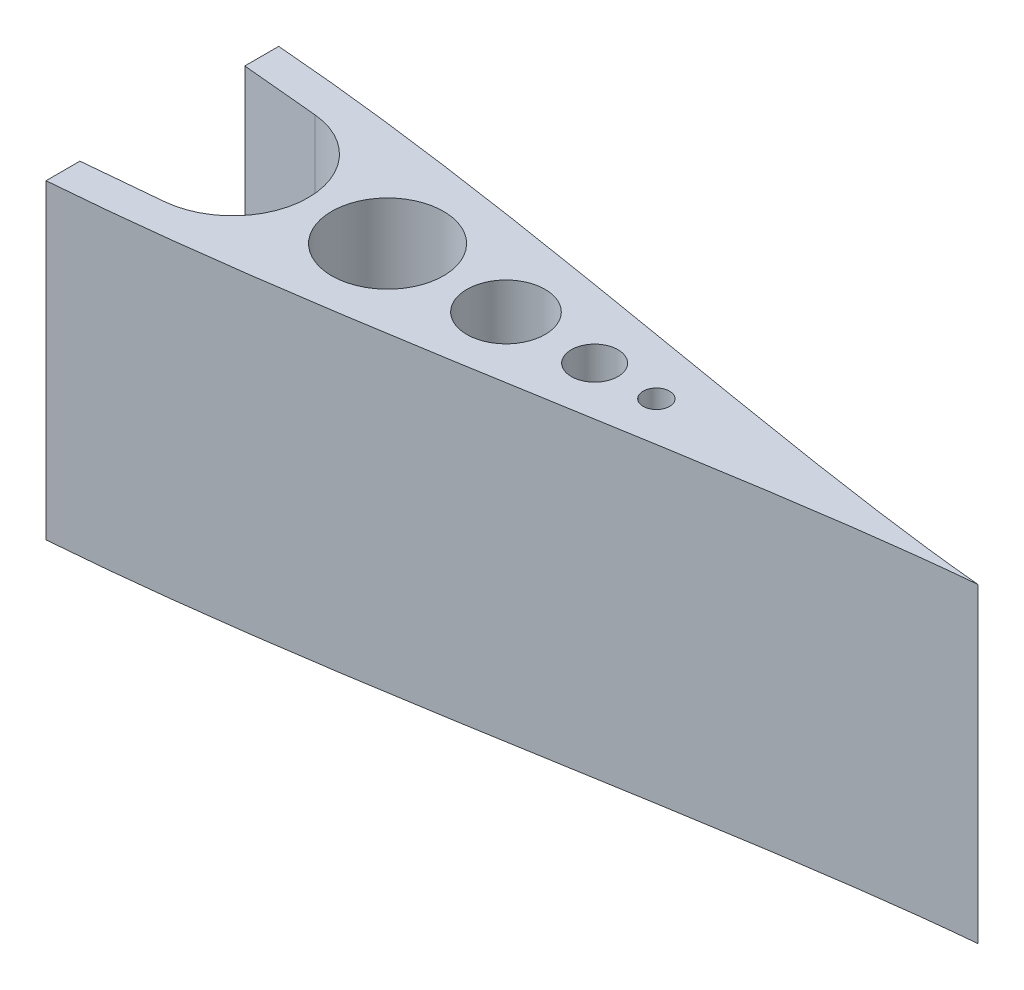
from build123d import *

# Parameters (mm, degrees)
SKETCH1_R           = 5.715
SKETCH1_R_2         = 9.131011462
SKETCH1_R_3         = 6.392333333
SKETCH1_R_4         = 3.81
SKETCH1_R_5         = 2.159
BOSS_EXTRUDE1_DEPTH = 50.8
CUT_EXTRUDE1_DEPTH  = 51.8000001


with BuildPart() as part:
    # Sketch1 → Boss-Extrude1 (new body)
    with BuildSketch(Plane(origin=(0, 0, 0), x_dir=(1, 0, 0), z_dir=(0, 1, 0))):
        with BuildLine():
            add(Edge.make_bspline(
                [(-106.482983395, 7e-09), (-106.481988205, 0.336221447), (-106.427915569, 1.172470852), (-106.105951464, 2.643099269), (-105.314009735, 4.475217408), (-103.897531119, 6.504348419), (-101.808045378, 8.571651332), (-99.066717841, 10.567556704), (-95.719803188, 12.4267473), (-91.817332429, 14.111441711), (-87.406701835, 15.599318162), (-82.531907012, 16.877133323), (-77.234149654, 17.93743562), (-71.552607098, 18.776740572), (-65.525147606, 19.395460586), (-59.188591418, 19.79657403), (-52.57905308, 19.986276316), (-45.732001964, 19.972865837), (-38.682363694, 19.76732247), (-31.464522928, 19.382552478), (-24.112335149, 18.833317467), (-16.659115821, 18.136000968), (-9.137634043, 17.308302017), (-1.580112881, 16.368906014), (5.98177291, 15.337213534), (13.516891029, 14.232999407), (20.994645609, 13.076129848), (28.384968739, 11.886210001), (35.658323251, 10.682336314), (42.785702907, 9.482759124), (49.738647425, 8.304637787), (56.489265684, 7.163760718), (63.010281114, 6.074356699), (69.275076728, 5.048841412), (75.257781106, 4.097692071), (80.933343311, 3.229317249), (86.277669376, 2.449846213), (91.267618323, 1.763292049), (95.881607116, 1.17122476), (100.098099776, 0.673119164), (103.673185129, 0.290516392), (105.83614122, 0.081745654), (106.733370691, 7e-09)],
                knots=[0.5, 0.5, 0.5, 0.5, 0.502166769, 0.505390167, 0.509655974, 0.514947682, 0.521244711, 0.528520886, 0.536744945, 0.54588136, 0.555890751, 0.566730119, 0.57835299, 0.590709588, 0.603747039, 0.617409572, 0.631638768, 0.646373793, 0.661551658, 0.677107483, 0.692974771, 0.709085713, 0.725371443, 0.741762353, 0.758188398, 0.774579367, 0.790865214, 0.806976332, 0.822843867, 0.838400002, 0.853578262, 0.868313774, 0.882543568, 0.896206835, 0.909245173, 0.92160287, 0.933227116, 0.944068236, 0.954079898, 0.963219316, 0.971447445, 0.977251074, 0.977251074, 0.977251074, 0.977251074], degree=3))
            add(Edge.make_bspline(
                [(-106.482983395, -7e-09), (-106.481988205, -0.336221447), (-106.427915569, -1.172470852), (-106.105951463, -2.643099269), (-105.314009735, -4.475217408), (-103.897531118, -6.504348419), (-101.808045378, -8.571651332), (-99.06671784, -10.567556704), (-95.719803188, -12.4267473), (-91.817332429, -14.111441711), (-87.406701835, -15.599318162), (-82.531907011, -16.877133323), (-77.234149654, -17.93743562), (-71.552607098, -18.776740572), (-65.525147605, -19.395460586), (-59.188591417, -19.79657403), (-52.57905308, -19.986276316), (-45.732001964, -19.972865837), (-38.682363694, -19.76732247), (-31.464522928, -19.382552478), (-24.112335148, -18.833317467), (-16.659115821, -18.136000968), (-9.137634043, -17.308302017), (-1.580112881, -16.368906014), (5.98177291, -15.337213534), (13.516891029, -14.232999407), (20.99464561, -13.076129848), (28.384968739, -11.886210001), (35.658323251, -10.682336314), (42.785702907, -9.482759124), (49.738647426, -8.304637787), (56.489265684, -7.163760718), (63.010281115, -6.074356699), (69.275076728, -5.048841412), (75.257781106, -4.097692071), (80.933343311, -3.229317249), (86.277669376, -2.449846213), (91.267618323, -1.763292049), (95.881607116, -1.17122476), (100.098099776, -0.673119164), (103.673185129, -0.290516392), (105.83614122, -0.081745654), (106.733370691, -7e-09)],
                knots=[0.5, 0.5, 0.5, 0.5, 0.502166769, 0.505390167, 0.509655974, 0.514947682, 0.521244711, 0.528520886, 0.536744945, 0.54588136, 0.555890751, 0.566730119, 0.57835299, 0.590709588, 0.603747039, 0.617409572, 0.631638768, 0.646373793, 0.661551658, 0.677107483, 0.692974771, 0.709085713, 0.725371443, 0.741762353, 0.758188398, 0.774579367, 0.790865214, 0.806976332, 0.822843867, 0.838400002, 0.853578262, 0.868313774, 0.882543568, 0.896206835, 0.909245173, 0.92160287, 0.933227116, 0.944068236, 0.954079898, 0.963219316, 0.971447445, 0.977251074, 0.977251074, 0.977251074, 0.977251074], degree=3))
        make_face()
        with BuildLine():
            ThreePointArc((-88.703779951, 0), (-92.937113284, -4.233333333), (-97.170446617, 0))
            ThreePointArc((-97.170446617, 0), (-92.937113284, 4.233333333), (-88.703779951, 0))
        make_face(mode=Mode.SUBTRACT)
        with Locations((-71.77044662, 0)):
            Circle(SKETCH1_R, mode=Mode.SUBTRACT)
        with BuildLine():
            ThreePointArc((-45.540838593, -15.24), (-60.780838593, 0), (-45.540838593, 15.24))
            ThreePointArc((-45.540838593, 15.24), (-44.126098565, 15.174192257), (-42.723576496, 14.977337356))
            Line((-42.723576496, 14.977337356), (-13.847320134, 12.285108666))
            ThreePointArc((-13.847320134, 12.285108666), (-2.65431439, 0), (-13.847320134, -12.285108666))
            Line((-13.847320134, -12.285108666), (-42.723576496, -14.977337356))
            ThreePointArc((-42.723576496, -14.977337356), (-44.126098565, -15.174192257), (-45.540838593, -15.24))
        make_face(mode=Mode.SUBTRACT)
        with Locations((10.310172634, 0)):
            Circle(SKETCH1_R_2, mode=Mode.SUBTRACT)
        with Locations((29.643517429, 0)):
            Circle(SKETCH1_R_3, mode=Mode.SUBTRACT)
        with Locations((44.126269567, 0)):
            Circle(SKETCH1_R_4, mode=Mode.SUBTRACT)
        with Locations((54.210398224, 0)):
            Circle(SKETCH1_R_5, mode=Mode.SUBTRACT)
        with BuildLine():
            add(Edge.make_bspline(
                [(-106.482983395, 7e-09), (-106.481988205, 0.336221447), (-106.427915569, 1.172470852), (-106.105951464, 2.643099269), (-105.314009735, 4.475217408), (-103.897531119, 6.504348419), (-101.808045378, 8.571651332), (-99.066717841, 10.567556704), (-95.719803188, 12.4267473), (-91.817332429, 14.111441711), (-87.406701835, 15.599318162), (-82.531907012, 16.877133323), (-77.234149654, 17.93743562), (-71.552607098, 18.776740572), (-65.525147606, 19.395460586), (-59.188591418, 19.79657403), (-52.57905308, 19.986276316), (-45.732001964, 19.972865837), (-38.682363694, 19.76732247), (-31.464522928, 19.382552478), (-24.112335149, 18.833317467), (-16.659115821, 18.136000968), (-9.137634043, 17.308302017), (-1.580112881, 16.368906014), (5.98177291, 15.337213534), (13.516891029, 14.232999407), (20.994645609, 13.076129848), (28.384968739, 11.886210001), (35.658323251, 10.682336314), (42.785702907, 9.482759124), (49.738647425, 8.304637787), (56.489265684, 7.163760718), (63.010281114, 6.074356699), (69.275076728, 5.048841412), (75.257781106, 4.097692071), (80.933343311, 3.229317249), (86.277669376, 2.449846213), (91.267618323, 1.763292049), (95.881607116, 1.17122476), (100.098099776, 0.673119164), (103.673185129, 0.290516392), (105.83614122, 0.081745654), (106.733370691, 7e-09)],
                knots=[0.5, 0.5, 0.5, 0.5, 0.502166769, 0.505390167, 0.509655974, 0.514947682, 0.521244711, 0.528520886, 0.536744945, 0.54588136, 0.555890751, 0.566730119, 0.57835299, 0.590709588, 0.603747039, 0.617409572, 0.631638768, 0.646373793, 0.661551658, 0.677107483, 0.692974771, 0.709085713, 0.725371443, 0.741762353, 0.758188398, 0.774579367, 0.790865214, 0.806976332, 0.822843867, 0.838400002, 0.853578262, 0.868313774, 0.882543568, 0.896206835, 0.909245173, 0.92160287, 0.933227116, 0.944068236, 0.954079898, 0.963219316, 0.971447445, 0.977251074, 0.977251074, 0.977251074, 0.977251074], degree=3))
            add(Edge.make_bspline(
                [(-106.482983395, -7e-09), (-106.481988205, -0.336221447), (-106.427915569, -1.172470852), (-106.105951463, -2.643099269), (-105.314009735, -4.475217408), (-103.897531118, -6.504348419), (-101.808045378, -8.571651332), (-99.06671784, -10.567556704), (-95.719803188, -12.4267473), (-91.817332429, -14.111441711), (-87.406701835, -15.599318162), (-82.531907011, -16.877133323), (-77.234149654, -17.93743562), (-71.552607098, -18.776740572), (-65.525147605, -19.395460586), (-59.188591417, -19.79657403), (-52.57905308, -19.986276316), (-45.732001964, -19.972865837), (-38.682363694, -19.76732247), (-31.464522928, -19.382552478), (-24.112335148, -18.833317467), (-16.659115821, -18.136000968), (-9.137634043, -17.308302017), (-1.580112881, -16.368906014), (5.98177291, -15.337213534), (13.516891029, -14.232999407), (20.99464561, -13.076129848), (28.384968739, -11.886210001), (35.658323251, -10.682336314), (42.785702907, -9.482759124), (49.738647426, -8.304637787), (56.489265684, -7.163760718), (63.010281115, -6.074356699), (69.275076728, -5.048841412), (75.257781106, -4.097692071), (80.933343311, -3.229317249), (86.277669376, -2.449846213), (91.267618323, -1.763292049), (95.881607116, -1.17122476), (100.098099776, -0.673119164), (103.673185129, -0.290516392), (105.83614122, -0.081745654), (106.733370691, -7e-09)],
                knots=[0.5, 0.5, 0.5, 0.5, 0.502166769, 0.505390167, 0.509655974, 0.514947682, 0.521244711, 0.528520886, 0.536744945, 0.54588136, 0.555890751, 0.566730119, 0.57835299, 0.590709588, 0.603747039, 0.617409572, 0.631638768, 0.646373793, 0.661551658, 0.677107483, 0.692974771, 0.709085713, 0.725371443, 0.741762353, 0.758188398, 0.774579367, 0.790865214, 0.806976332, 0.822843867, 0.838400002, 0.853578262, 0.868313774, 0.882543568, 0.896206835, 0.909245173, 0.92160287, 0.933227116, 0.944068236, 0.954079898, 0.963219316, 0.971447445, 0.977251074, 0.977251074, 0.977251074, 0.977251074], degree=3))
        make_face()
        with BuildLine():
            ThreePointArc((-88.703779951, 0), (-92.937113284, -4.233333333), (-97.170446617, 0))
            ThreePointArc((-97.170446617, 0), (-92.937113284, 4.233333333), (-88.703779951, 0))
        make_face(mode=Mode.SUBTRACT)
        with Locations((-71.77044662, 0)):
            Circle(SKETCH1_R, mode=Mode.SUBTRACT)
        with BuildLine():
            ThreePointArc((-45.540838593, -15.24), (-60.780838593, 0), (-45.540838593, 15.24))
            ThreePointArc((-45.540838593, 15.24), (-44.126098565, 15.174192257), (-42.723576496, 14.977337356))
            Line((-42.723576496, 14.977337356), (-13.847320134, 12.285108666))
            ThreePointArc((-13.847320134, 12.285108666), (-2.65431439, 0), (-13.847320134, -12.285108666))
            Line((-13.847320134, -12.285108666), (-42.723576496, -14.977337356))
            ThreePointArc((-42.723576496, -14.977337356), (-44.126098565, -15.174192257), (-45.540838593, -15.24))
        make_face(mode=Mode.SUBTRACT)
        with Locations((10.310172634, 0)):
            Circle(SKETCH1_R_2, mode=Mode.SUBTRACT)
        with Locations((29.643517429, 0)):
            Circle(SKETCH1_R_3, mode=Mode.SUBTRACT)
        with Locations((44.126269567, 0)):
            Circle(SKETCH1_R_4, mode=Mode.SUBTRACT)
        with Locations((54.210398224, 0)):
            Circle(SKETCH1_R_5, mode=Mode.SUBTRACT)
    extrude(amount=BOSS_EXTRUDE1_DEPTH)

    # Sketch2 → Cut-Extrude1 (cut, through all)
    with BuildSketch(Plane(origin=(0, 50.8, 0), x_dir=(1, 0, 0), z_dir=(0, 1, 0))):
        with BuildLine():
            Line((-26.472983395, 19.001478059), (-26.472983395, -19.001478059))
            add(Edge.make_bspline(
                [(-106.482983395, -7e-09), (-106.481988205, -0.336221447), (-106.427915569, -1.172470852), (-106.105951463, -2.643099269), (-105.314009735, -4.475217408), (-103.897531118, -6.504348419), (-101.808045378, -8.571651332), (-99.06671784, -10.567556704), (-95.719803188, -12.4267473), (-91.817332429, -14.111441711), (-87.406701835, -15.599318162), (-82.531907011, -16.877133323), (-77.234149654, -17.93743562), (-71.552607098, -18.776740572), (-65.525147605, -19.395460586), (-59.188591417, -19.79657403), (-52.57905308, -19.986276316), (-45.732001964, -19.972865837), (-38.682363694, -19.76732247), (-32.239689792, -19.423875217), (-28.152608898, -19.132499029), (-26.472983395, -19.001478059)],
                knots=[0.5, 0.5, 0.5, 0.5, 0.502166769, 0.505390167, 0.509655974, 0.514947682, 0.521244711, 0.528520886, 0.536744945, 0.54588136, 0.555890751, 0.566730119, 0.57835299, 0.590709588, 0.603747039, 0.617409572, 0.631638768, 0.646373793, 0.661551658, 0.677107483, 0.687970015, 0.687970015, 0.687970015, 0.687970015], degree=3))
            add(Edge.make_bspline(
                [(-106.482983395, -7e-09), (-106.481988205, 0.336221447), (-106.427915569, 1.172470852), (-106.105951464, 2.643099269), (-105.314009735, 4.475217408), (-103.897531119, 6.504348419), (-101.808045378, 8.571651332), (-99.066717841, 10.567556704), (-95.719803188, 12.4267473), (-91.817332429, 14.111441711), (-87.406701835, 15.599318162), (-82.531907012, 16.877133323), (-77.234149654, 17.93743562), (-71.552607098, 18.776740572), (-65.525147606, 19.395460586), (-59.188591418, 19.79657403), (-52.57905308, 19.986276316), (-45.732001964, 19.972865837), (-38.682363694, 19.76732247), (-32.239689792, 19.423875217), (-28.152608898, 19.132499029), (-26.472983395, 19.001478059)],
                knots=[0.5, 0.5, 0.5, 0.5, 0.502166769, 0.505390167, 0.509655974, 0.514947682, 0.521244711, 0.528520886, 0.536744945, 0.54588136, 0.555890751, 0.566730119, 0.57835299, 0.590709588, 0.603747039, 0.617409572, 0.631638768, 0.646373793, 0.661551658, 0.677107483, 0.687970015, 0.687970015, 0.687970015, 0.687970015], degree=3))
        make_face()
    extrude(amount=-CUT_EXTRUDE1_DEPTH, mode=Mode.SUBTRACT)


solid = part.part
